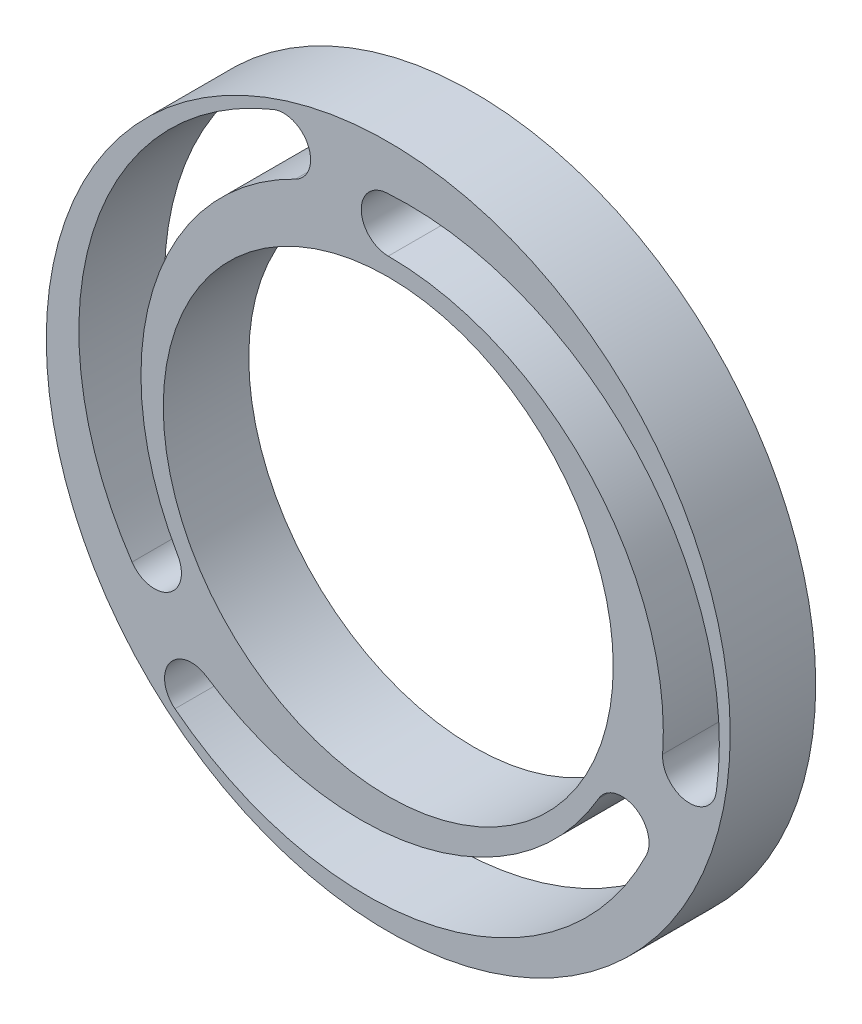
from build123d import *

# Parameters (mm, degrees)
SKETCH2_R           = 38
SKETCH2_R_2         = 25
BOSS_EXTRUDE2_DEPTH = 9.5
CUT_EXTRUDE1_DEPTH  = 9.5
CIRPATTERN1_COUNT   = 3


with BuildPart() as part:
    # Sketch2 → Boss-Extrude2 (new body)
    with BuildSketch(Plane.XY):
        Circle(SKETCH2_R)
        Circle(SKETCH2_R_2, mode=Mode.SUBTRACT)
    extrude(amount=BOSS_EXTRUDE2_DEPTH)

    # Sketch1 → Cut-Extrude1 (cut)
    with BuildSketch(Plane.XY):
        with BuildLine():
            ThreePointArc((-0.208321274, 32.992758301), (-2.998189029, 29.895776448), (0, 27))
            ThreePointArc((0, 27), (22.353121455, 17.28106259), (30.490756455, -5.694983191))
            ThreePointArc((30.490756455, -5.694983191), (33.17056476, -8.887675806), (36.454429797, -6.320403108))
            ThreePointArc((36.454429797, -6.320403108), (27.494508002, 22.075827712), (-0.208321274, 32.992758301))
        make_face()
    cut_extrude1 = extrude(amount=CUT_EXTRUDE1_DEPTH, mode=Mode.SUBTRACT)

    # CirPattern1: Cut-Extrude1 ×3 about axis
    cirpattern1_axis = Axis((0, 0, 9.5), (0, 0, -1))
    for i in range(1, CIRPATTERN1_COUNT):
        add(cut_extrude1.rotate(cirpattern1_axis, i * 360 / CIRPATTERN1_COUNT), mode=Mode.SUBTRACT)


solid = part.part
